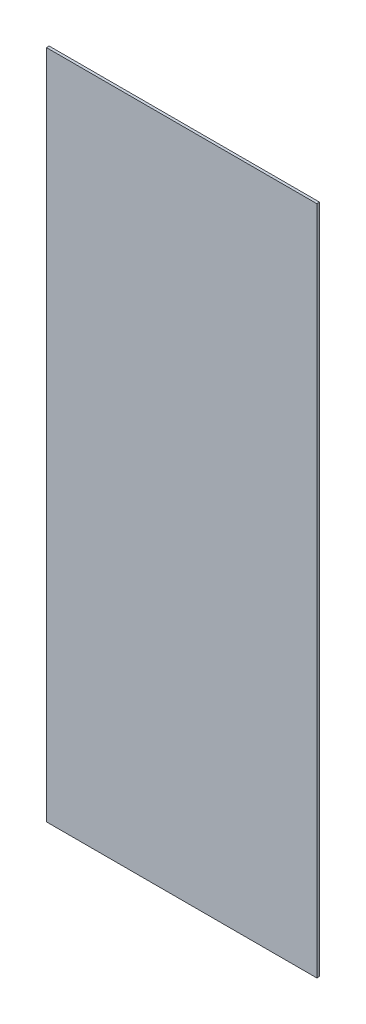
from build123d import *

# Parameters (mm, degrees)
SKETCH1_W           = 200
SKETCH1_H           = 496
BOSS_EXTRUDE1_DEPTH = 2


with BuildPart() as part:
    # Sketch1 → Boss-Extrude1 (new body)
    with BuildSketch(Plane.XY):
        Rectangle(SKETCH1_W, SKETCH1_H)
    extrude(amount=BOSS_EXTRUDE1_DEPTH)


solid = part.part
